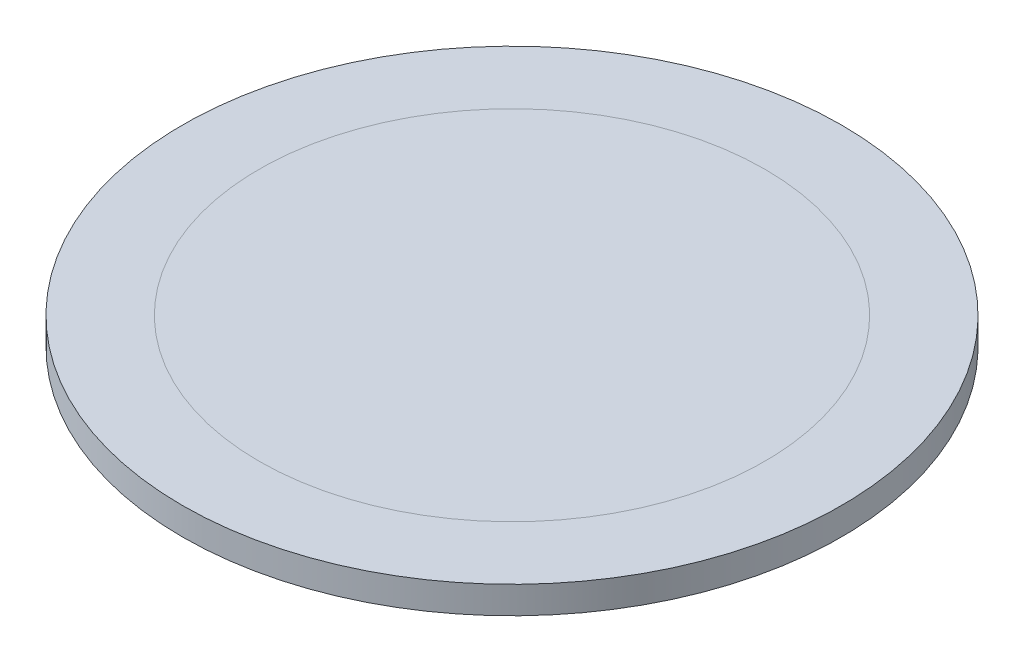
from build123d import *

# Parameters (mm, degrees)
SKIZZE1_R                       = 21.5
SKIZZE1_R_2                     = 16.5
AUFSATZ_LINEAR_AUSTRAGEN1_DEPTH = 1.78


with BuildPart() as part:
    # Skizze1 → Aufsatz-Linear austragen1 (new body)
    with BuildSketch(Plane(origin=(0, 0, 0), x_dir=(1, 0, 0), z_dir=(0, 1, 0))):
        with Locations(Location((0, 0, 0), (0, 0, 270))):
            Circle(SKIZZE1_R)
        Circle(SKIZZE1_R_2, mode=Mode.SUBTRACT)
        Circle(SKIZZE1_R_2)
    extrude(amount=AUFSATZ_LINEAR_AUSTRAGEN1_DEPTH)


solid = part.part
